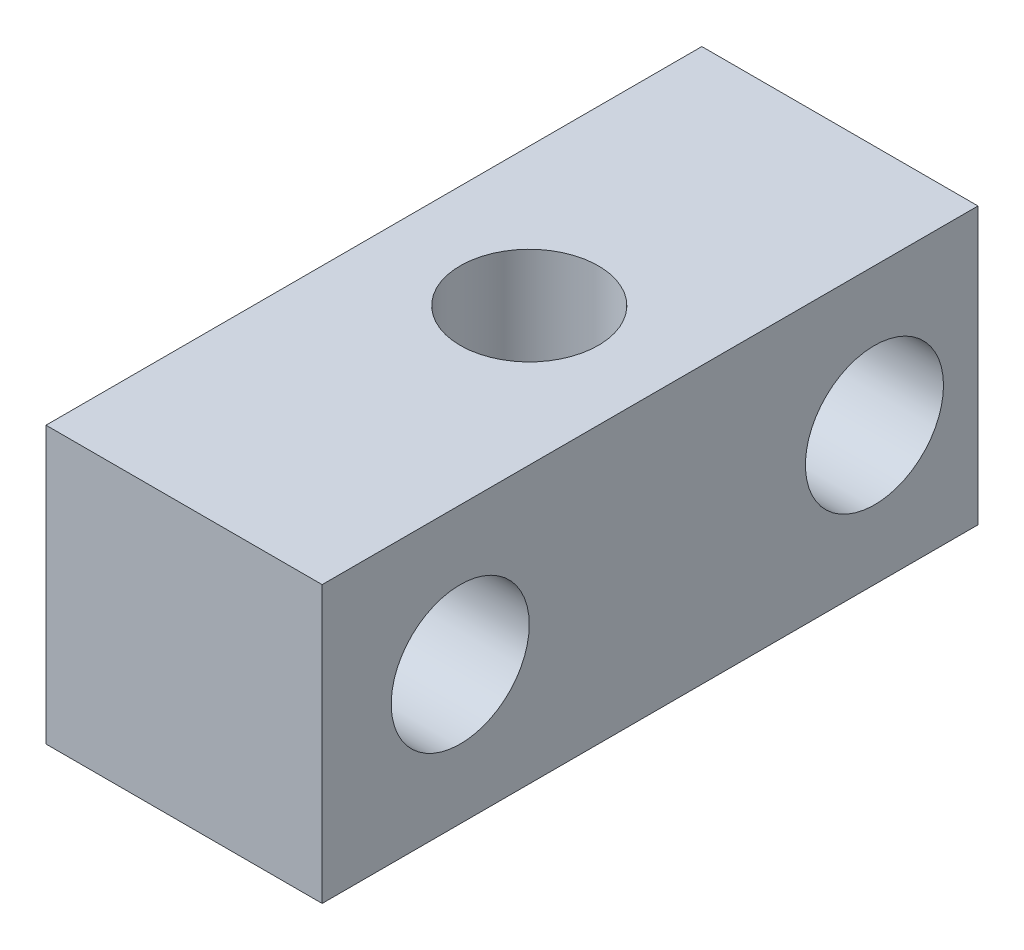
from build123d import *

# Parameters (mm, degrees)
SKETCH1_W               = 12.7
SKETCH1_H               = 12.7
BOSS_EXTRUDE1_DEPTH     = 34.925
F_1_4_20_TAPPED_HOLE1_D = 6.35
F_1_4_20_TAPPED_HOLE2_D = 6.35
SKETCH6_W               = 12.7
SKETCH6_H               = 39.6875
SKETCH6_R               = 3.175
CUT_EXTRUDE1_DEPTH      = 13.7


with BuildPart() as part:
    # Sketch1 → Boss-Extrude1 (new body, symmetric)
    with BuildSketch(Plane.XY):
        Rectangle(SKETCH1_W, SKETCH1_H)
    extrude(amount=BOSS_EXTRUDE1_DEPTH, both=True)

    # 1/4-20 Tapped Hole1 (through all)
    with Locations(Plane(origin=(0, 6.35, 0), x_dir=(1, 0, 0), z_dir=(0, 1, 0))):
        with Locations((0, 0), (0, 19.05), (0, -19.05)):
            Hole(F_1_4_20_TAPPED_HOLE1_D / 2)

    # 1/4-20 Tapped Hole2 (through all)
    with Locations(Plane(origin=(6.35, 0, 0), x_dir=(0, 0, -1), z_dir=(1, 0, 0))):
        with Locations((9.525, 0), (28.575, 0), (-9.525, 0), (-28.575, 0)):
            Hole(F_1_4_20_TAPPED_HOLE2_D / 2)

    # Sketch6 → Cut-Extrude1 (cut, through all)
    with BuildSketch(Plane(origin=(0, 6.35, 0), x_dir=(1, 0, 0), z_dir=(0, 1, 0))):
        with Locations((0, 15.08125)):
            Rectangle(SKETCH6_W, SKETCH6_H)
        Circle(SKETCH6_R, mode=Mode.SUBTRACT)
        with Locations((0, 19.05)):
            Circle(SKETCH6_R, mode=Mode.SUBTRACT)
    extrude(amount=-CUT_EXTRUDE1_DEPTH, mode=Mode.SUBTRACT)


solid = part.part
